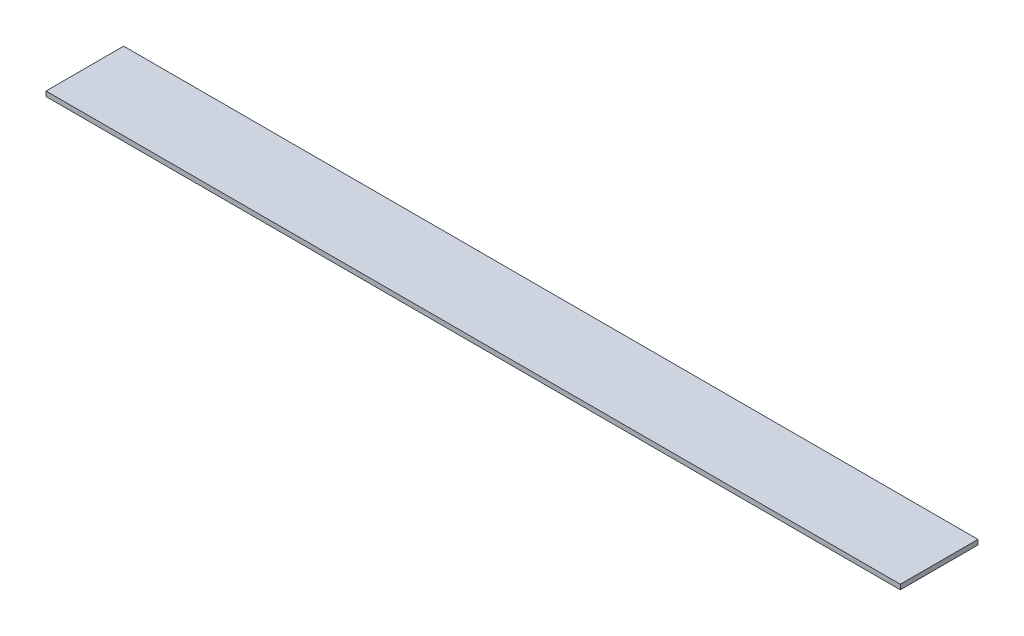
from build123d import *

# Parameters (mm, degrees)
SKETCH1_W           = 558.8
SKETCH1_H           = 50.8
BOSS_EXTRUDE1_DEPTH = 3.175


with BuildPart() as part:
    # Sketch1 → Boss-Extrude1 (new body)
    with BuildSketch(Plane.XZ.offset(80.26236602)):
        with Locations((279.4, 25.4)):
            Rectangle(SKETCH1_W, SKETCH1_H)
    extrude(amount=BOSS_EXTRUDE1_DEPTH)


solid = part.part
